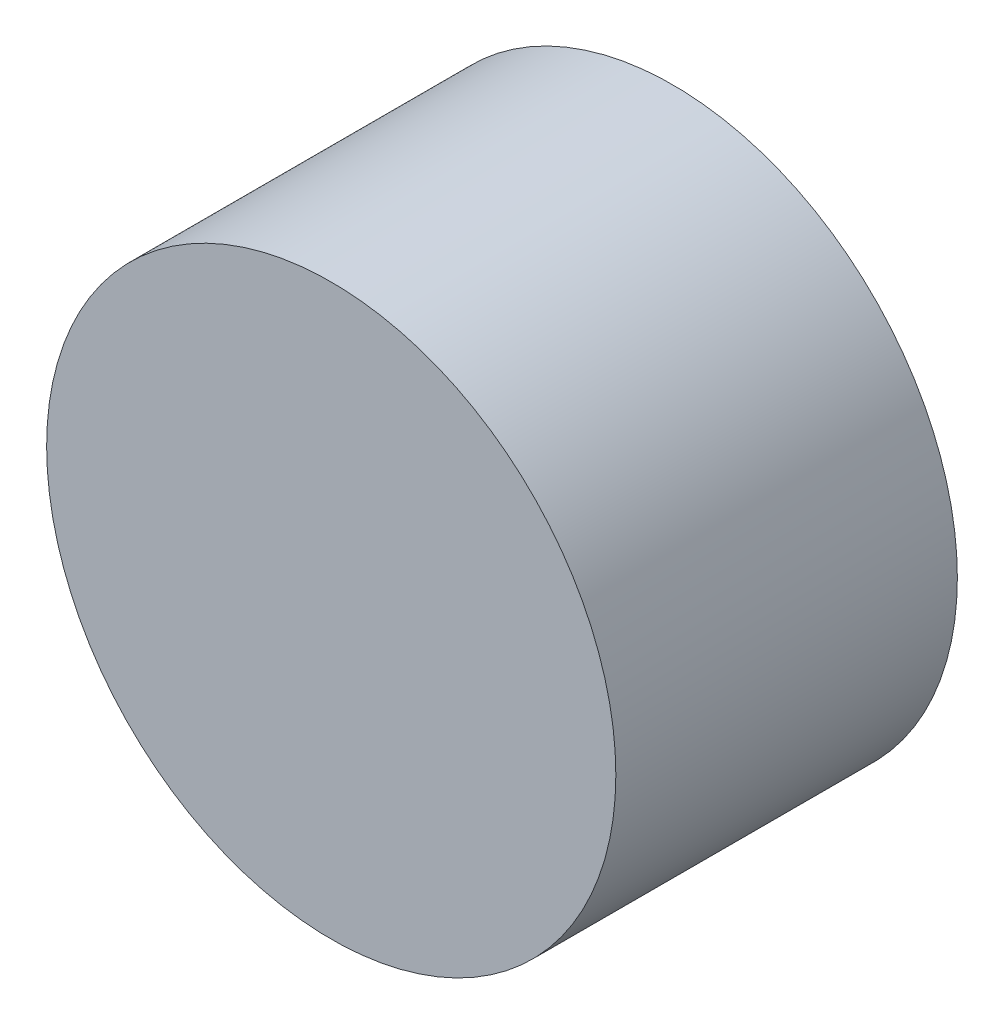
from build123d import *

# Parameters (mm, degrees)
SCHIZZO1_R                   = 25
ESTRUSIONE_ESTRUSIONE1_DEPTH = 30


with BuildPart() as part:
    # Schizzo1 → Estrusione-Estrusione1 (new body)
    with BuildSketch(Plane.XY):
        Circle(SCHIZZO1_R)
    extrude(amount=ESTRUSIONE_ESTRUSIONE1_DEPTH)


solid = part.part
